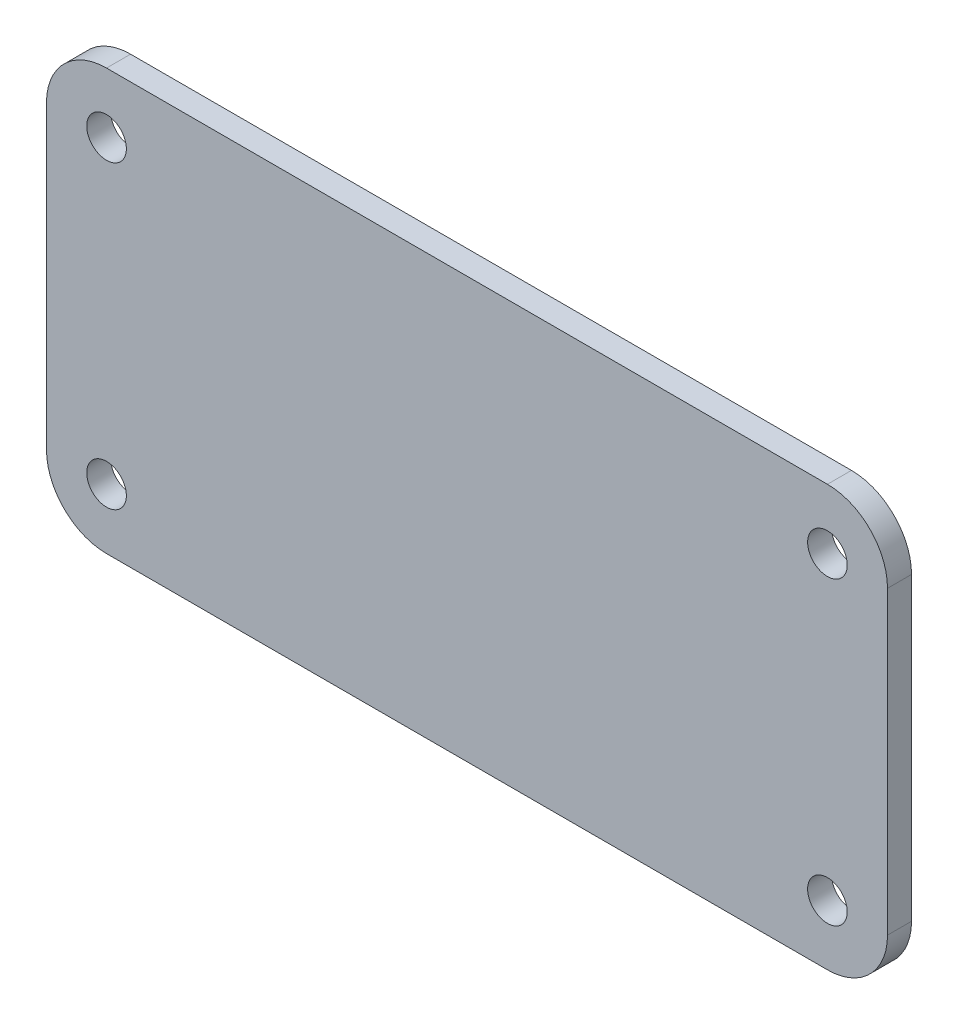
from build123d import *

# Parameters (mm, degrees)
SKETCH_1_W          = 70
SKETCH_1_H          = 35
EXTRUDE_1_DEPTH     = 2
FILLET_1_R          = 5
SKETCH_2_R          = 1.65
CUT_EXTRUDE_1_DEPTH = 2


with BuildPart() as part:
    # 草图1 → 凸台-拉伸1 (new body)
    with BuildSketch(Plane.XY):
        with Locations((35, 17.5)):
            Rectangle(SKETCH_1_W, SKETCH_1_H)
    extrude(amount=EXTRUDE_1_DEPTH)

    # 圆角1
    fillet_1_edges = [part.edges().sort_by_distance(p)[0] for p in [
        (0, 35, 1),
        (70, 35, 1),
        (70, 0, 1),
        (0, 0, 1),
    ]]
    fillet(fillet_1_edges, radius=FILLET_1_R)

    # 草图2 → 切除-拉伸1 (cut)
    with BuildSketch(Plane.XY.offset(2)):
        with Locations((5, 30)):
            Circle(SKETCH_2_R)
        with Locations((5, 5)):
            Circle(SKETCH_2_R)
        with Locations((65, 5)):
            Circle(SKETCH_2_R)
        with Locations((65, 30)):
            Circle(SKETCH_2_R)
    extrude(amount=-CUT_EXTRUDE_1_DEPTH, mode=Mode.SUBTRACT)


solid = part.part
